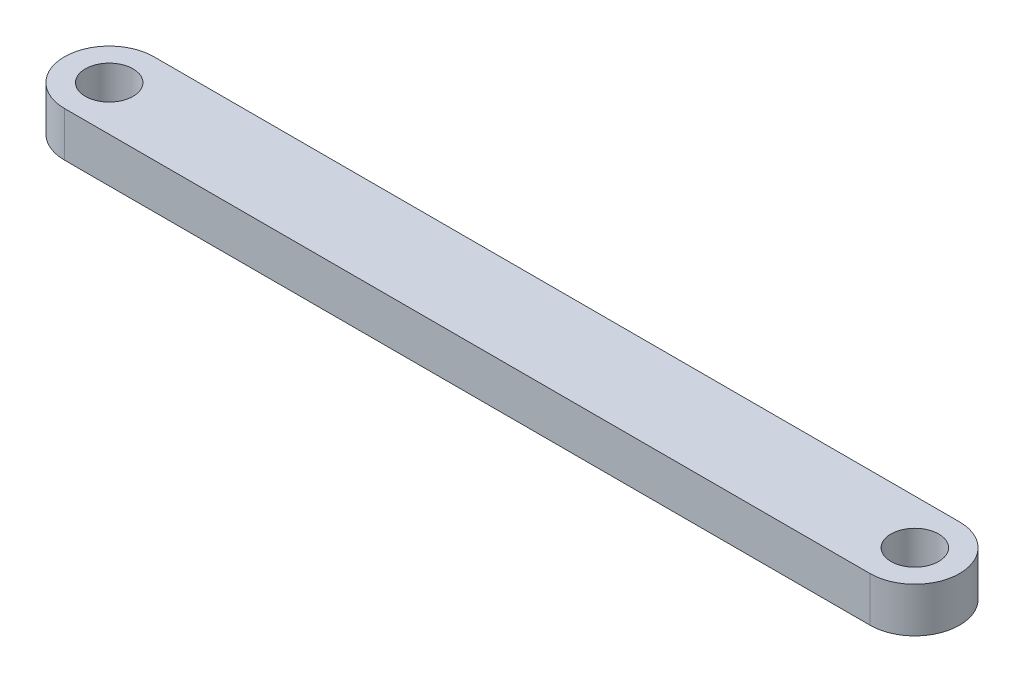
from build123d import *

# Parameters (mm, degrees)
EXTRUDE_1_DEPTH     = 3
SKETCH_2_R          = 1.6
CUT_EXTRUDE_1_DEPTH = 4


with BuildPart() as part:
    # 草图1 → 凸台-拉伸1 (new body)
    with BuildSketch(Plane(origin=(0, 0, 0), x_dir=(1, 0, 0), z_dir=(0, 1, 0))):
        with BuildLine():
            Line((-54, -3), (0, -3))
            ThreePointArc((0, -3), (3, 0), (0, 3))
            Line((0, 3), (-54, 3))
            ThreePointArc((-54, 3), (-57, 0), (-54, -3))
        make_face()
    extrude(amount=EXTRUDE_1_DEPTH)

    # 草图2 → 切除-拉伸1 (cut, through all)
    with BuildSketch(Plane(origin=(0, 3, 0), x_dir=(1, 0, 0), z_dir=(0, 1, 0))):
        with Locations((-54, 0)):
            Circle(SKETCH_2_R)
        Circle(SKETCH_2_R)
    extrude(amount=-CUT_EXTRUDE_1_DEPTH, mode=Mode.SUBTRACT)


solid = part.part
